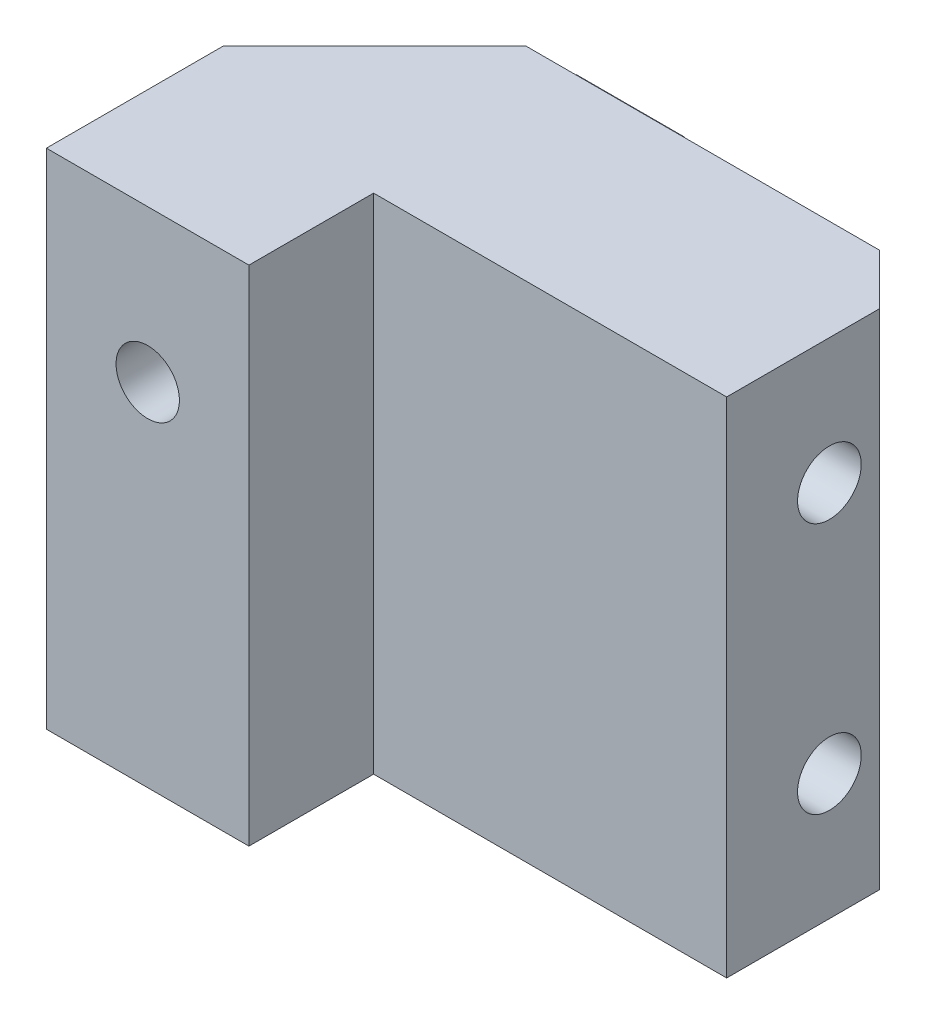
from build123d import *

# Parameters (mm, degrees)
BOSS_EXTRUDE1_DEPTH      = 15.8
BOSS_EXTRUDE1_DEPTH_BACK = 15.8
SKETCH2_R                = 1.99
CUT_EXTRUDE1_DEPTH       = 6.15
SKETCH3_R                = 2
CUT_EXTRUDE2_DEPTH       = 16.2
SKETCH4_W                = 6.815
SKETCH4_H                = 30.47
BOSS_EXTRUDE2_DEPTH      = 0.86


with BuildPart() as part:
    # Sketch1 → Boss-Extrude1 (new, two sides: drawn at the far end of the back side and taken through both)
    with BuildSketch(Plane(origin=(0, 0, 0), x_dir=(1, 0, 0), z_dir=(0, 1, 0)).offset(-BOSS_EXTRUDE1_DEPTH_BACK)):
        Polygon((-6.365, 0), (6.355, 0), (6.355, 7.83), (28.525, 7.83), (28.525, 17.435), (25.35, 20.61), (3.135, 20.61), (-6.365, 11.11), align=None)
    extrude(amount=BOSS_EXTRUDE1_DEPTH + BOSS_EXTRUDE1_DEPTH_BACK)

    # Sketch2 → Cut-Extrude1 (cut)
    with BuildSketch(Plane.XY):
        with Locations((0, 6.26)):
            Circle(SKETCH2_R)
    extrude(amount=-CUT_EXTRUDE1_DEPTH, mode=Mode.SUBTRACT)

    # Sketch3 → Cut-Extrude2 (cut)
    with BuildSketch(Plane(origin=(28.525, 0, 0), x_dir=(0, 0, -1), z_dir=(1, 0, 0))):
        with Locations((14.28, -7.91)):
            Circle(SKETCH3_R)
        with Locations((14.28, 7.91)):
            Circle(SKETCH3_R)
    extrude(amount=-CUT_EXTRUDE2_DEPTH, mode=Mode.SUBTRACT)


with BuildPart() as body_2:
    # Sketch4 → Boss-Extrude2 (new body)
    with BuildSketch(Plane(origin=(0, 0, -20.61), x_dir=(-1, 0, 0), z_dir=(0, 0, -1))):
        with Locations((-8.8425, -0.265)):
            Rectangle(SKETCH4_W, SKETCH4_H)
    extrude(amount=BOSS_EXTRUDE2_DEPTH)


solid = Compound([part.part, body_2.part])
